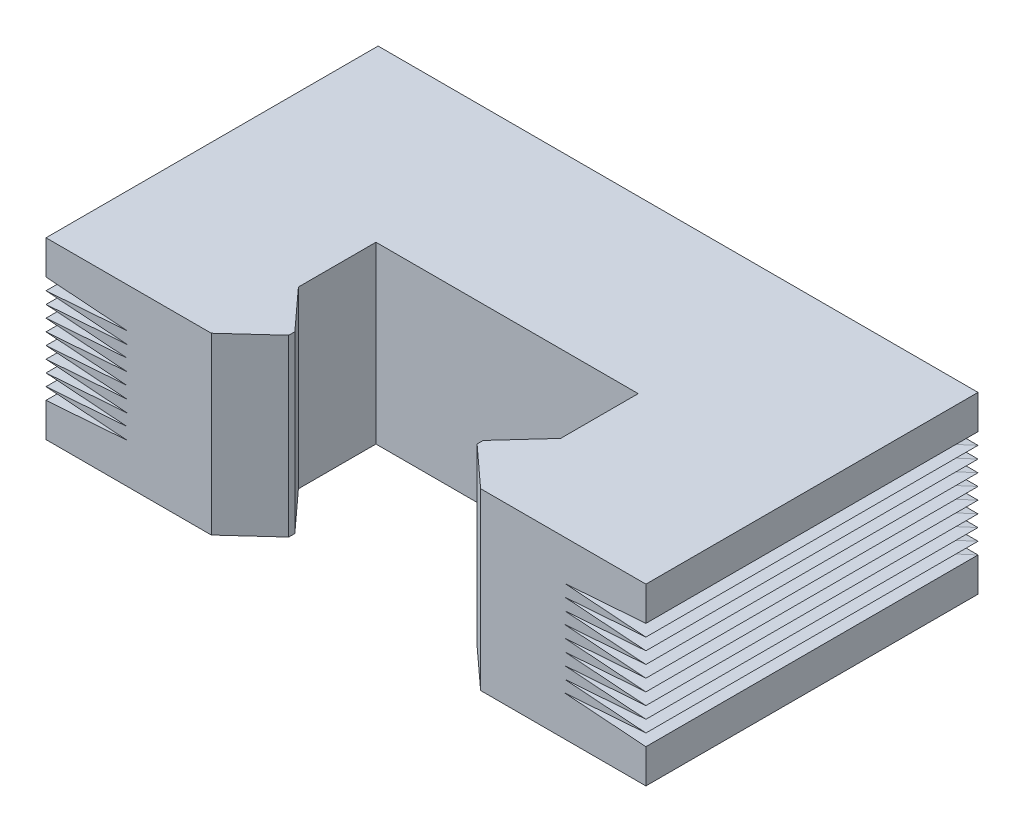
from build123d import *

# Parameters (mm, degrees)
BOSS_EXTRUDE1_DEPTH     = 16.316743
CUT_EXTRUDE1_DEPTH      = 16.04
CUT_EXTRUDE1_DEPTH_BACK = 16.96
CUT_EXTRUDE2_DEPTH      = 29
CUT_EXTRUDE2_DEPTH_BACK = 29


with BuildPart() as part:
    # Sketch3 → Boss-Extrude1 (new body)
    with BuildSketch(Plane(origin=(0, 0, 0), x_dir=(1, 0, 0), z_dir=(0, 1, 0))):
        Polygon((-28, 15.96), (28, 15.96), (28, -15.04), (12.57, -15.04), (8.79, -11.59), (8.79, -11.02), (12.24, -7.24), (12.24, 0), (-12.24, 0), (-12.24, -7.24), (-8.79, -11.02), (-8.79, -11.59), (-12.57, -15.04), (-28, -15.04), align=None)
    extrude(amount=-BOSS_EXTRUDE1_DEPTH)

    # Sketch4 → Cut-Extrude1 (cut, two sides)
    with BuildSketch(Plane.XY) as cut_extrude1_sk:
        Polygon((28, -3.175), (28, -4.282415891), (20.400144244, -3.728707945), align=None)
        Polygon((28, -4.282415891), (28, -5.389831781), (20.400144244, -4.836123836), align=None)
        Polygon((28, -5.389831781), (28, -6.497247672), (20.400144244, -5.943539726), align=None)
        Polygon((28, -6.497247672), (28, -7.604663562), (20.400144244, -7.050955617), align=None)
        Polygon((28, -7.604663562), (28, -8.712079453), (20.400144244, -8.158371507), align=None)
        Polygon((28, -8.712079453), (28, -9.819495343), (20.400144244, -9.265787398), align=None)
        Polygon((20.400144244, -10.373203288), (28, -10.926911234), (28, -9.819495343), align=None)
        Polygon((28, -10.926911234), (28, -12.034327124), (20.400144244, -11.480619179), align=None)
        Polygon((28, -12.034327124), (28, -13.141743015), (20.400144244, -12.588035069), align=None)
        Polygon((-28, -13.141743015), (-28, -12.034327124), (-20.400144244, -12.588035069), align=None)
        Polygon((-28, -10.926911234), (-20.400144244, -11.480619179), (-28, -12.034327124), align=None)
        Polygon((-28, -10.926911234), (-28, -9.819495343), (-20.400144244, -10.373203288), align=None)
        Polygon((-28, -8.712079453), (-20.400144244, -9.265787398), (-28, -9.819495343), align=None)
        Polygon((-28, -7.604663562), (-20.400144244, -8.158371507), (-28, -8.712079453), align=None)
        Polygon((-28, -6.497247672), (-20.400144244, -7.050955617), (-28, -7.604663562), align=None)
        Polygon((-28, -5.389831781), (-20.400144244, -5.943539726), (-28, -6.497247672), align=None)
        Polygon((-28, -4.282415891), (-20.400144244, -4.836123836), (-28, -5.389831781), align=None)
        Polygon((-28, -3.175), (-20.400144244, -3.728707945), (-28, -4.282415891), align=None)
    extrude(amount=CUT_EXTRUDE1_DEPTH, mode=Mode.SUBTRACT)
    extrude(cut_extrude1_sk.sketch, amount=-CUT_EXTRUDE1_DEPTH_BACK, mode=Mode.SUBTRACT)

    # Sketch5 → Cut-Extrude2 (cut, two sides)
    with BuildSketch(Plane(origin=(0, 0, 0), x_dir=(0, 0, -1), z_dir=(1, 0, 0))) as cut_extrude2_sk:
        Polygon((15.96, -3.175), (15.96, -4.282415891), (8.360144244, -3.728707945), align=None)
        Polygon((8.360144244, -4.836123836), (15.96, -5.389831781), (15.96, -4.282415891), align=None)
        Polygon((15.96, -5.389831781), (15.96, -6.497247672), (8.360144244, -5.943539726), align=None)
        Polygon((8.360144244, -7.050955617), (15.96, -7.604663562), (15.96, -6.497247672), align=None)
        Polygon((15.96, -7.604663562), (15.96, -8.712079453), (8.360144244, -8.158371507), align=None)
        Polygon((8.360144244, -9.265787398), (15.96, -9.819495343), (15.96, -8.712079453), align=None)
        Polygon((15.96, -9.819495343), (15.96, -10.926911234), (8.360144244, -10.373203288), align=None)
        Polygon((8.360144244, -11.480619179), (15.96, -12.034327124), (15.96, -10.926911234), align=None)
        Polygon((15.96, -12.034327124), (15.96, -13.141743015), (8.360144244, -12.588035069), align=None)
    extrude(amount=CUT_EXTRUDE2_DEPTH, mode=Mode.SUBTRACT)
    extrude(cut_extrude2_sk.sketch, amount=-CUT_EXTRUDE2_DEPTH_BACK, mode=Mode.SUBTRACT)


solid = part.part
